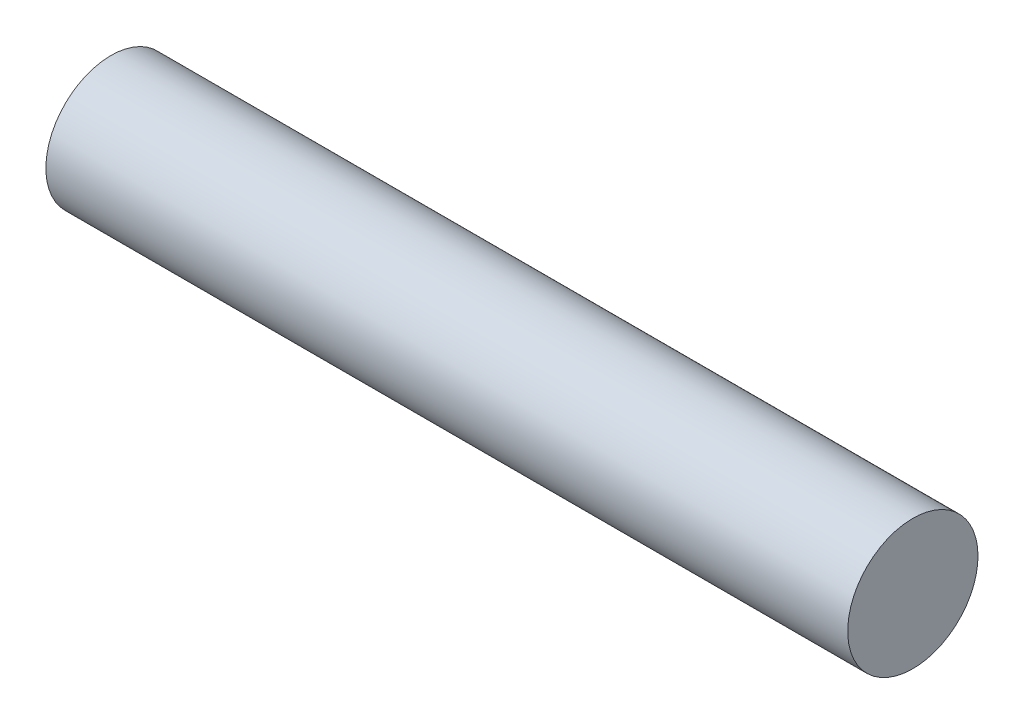
from build123d import *

# Parameters (mm, degrees)
SKETCH1_R           = 3.25
BOSS_EXTRUDE1_DEPTH = 20


with BuildPart() as part:
    # Sketch1 → Boss-Extrude1 (new body, symmetric)
    with BuildSketch(Plane(origin=(0, 0, 0), x_dir=(0, 0, -1), z_dir=(1, 0, 0))):
        Circle(SKETCH1_R)
    extrude(amount=BOSS_EXTRUDE1_DEPTH, both=True)


solid = part.part
